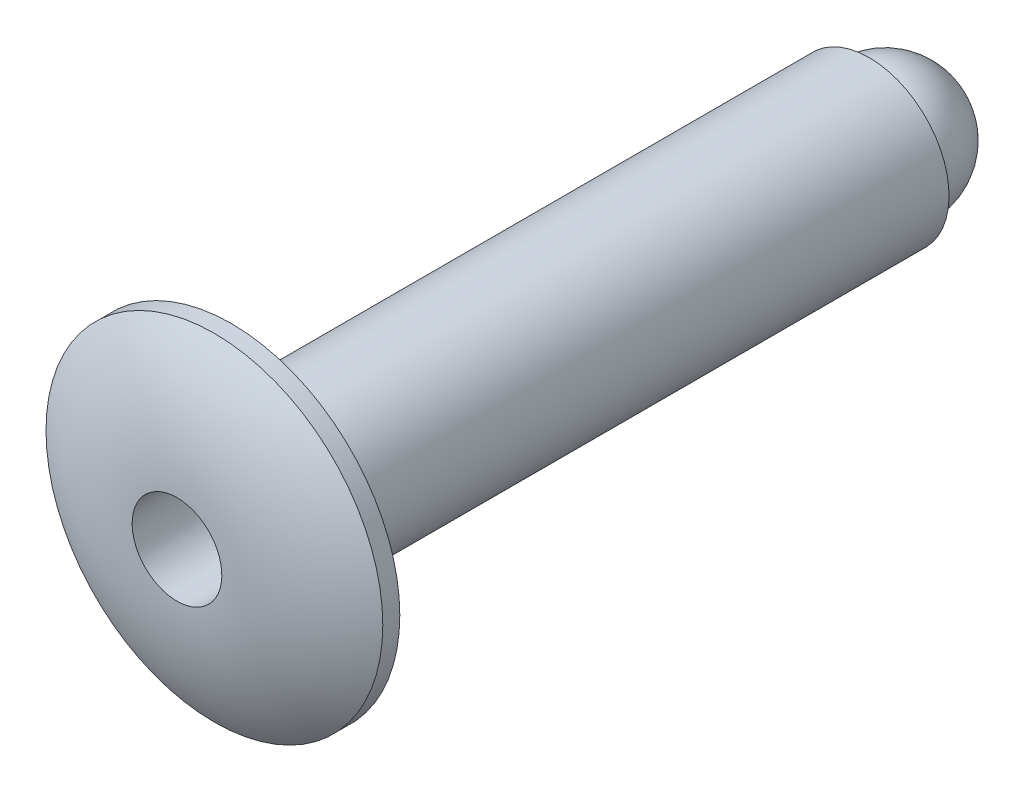
from build123d import *

# Parameters (mm, degrees)
FILLET2_R = 0.254


with BuildPart() as part:
    # Sketch2 → Revolve1 (revolve)
    with BuildSketch(Plane(origin=(0, 0, 0), x_dir=(0, 0, -1), z_dir=(1, 0, 0))):
        with BuildLine():
            Line((9.525, 1.190625), (0, 1.190625))
            Line((0, 1.190625), (0, 2.5146))
            Line((0, 2.5146), (-0.254, 2.5146))
            ThreePointArc((-0.254, 2.5146), (-0.670034887, 1.633549088), (-0.8128, 0.669726562))
            Line((-0.8128, 0.669726562), (0, 0.669726563))
            Line((0, 0.669726563), (0.9525, 0.669726563))
            Line((0.9525, 0.669726563), (0.9525, 0))
            Line((0.9525, 0), (9.525, 0))
            Line((9.525, 0), (9.525, 1.190625))
        make_face()
    revolve(axis=Axis((0, 0, -9.525), (0, 0, 1)))

    # Fillet2
    fillet2_edges = [part.edges().sort_by_distance(p)[0] for p in [
        (0, -1.190625, 0),
    ]]
    fillet(fillet2_edges, radius=FILLET2_R)


with BuildPart() as body_2:
    # Sketch8 → Revolve3 (revolve)
    with BuildSketch(Plane(origin=(0, 0, 0), x_dir=(0, 0, -1), z_dir=(1, 0, 0))):
        with BuildLine():
            Line((9.525, 0.9525), (9.525, 0))
            Line((9.525, 0), (10.7442, 0))
            ThreePointArc((10.7442, 0), (10.366889167, 0.773580133), (9.525, 0.9525))
        make_face()
    revolve(axis=Axis((0, 0, -9.525), (0, 0, -1)))


solid = Compound([part.part, body_2.part])
